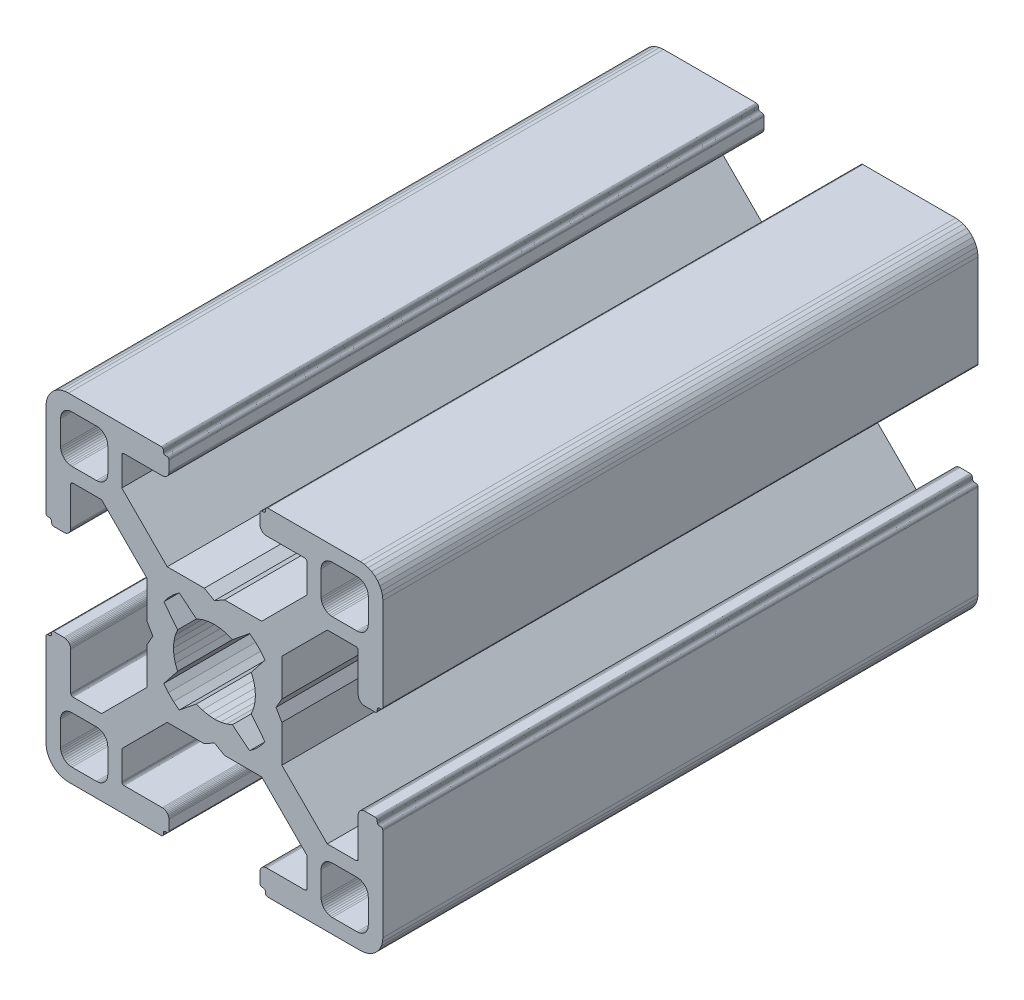
from build123d import *

# Parameters (mm, degrees)
BOSS_EXTRUDE1_DEPTH = 53


with BuildPart() as part:
    # Sketch1 → Boss-Extrude1 (new body)
    with BuildSketch(Plane.XY):
        Polygon((28.34729664, 29.969613999), (28.000000864, 29.999999329), (19.750000909, 29.999999329), (19.715268165, 29.996961355), (19.681595266, 29.987938702), (19.649999216, 29.973205179), (19.621443003, 29.953207821), (19.596790895, 29.928557575), (19.576793537, 29.899999499), (19.562061876, 29.868405312), (19.55303736, 29.834728688), (19.549999386, 29.799999669), (19.549999386, 29.699999839), (19.546961412, 29.665268958), (19.537936896, 29.631596059), (19.523203373, 29.599998146), (19.503207877, 29.571441934), (19.478557631, 29.546789825), (19.449999556, 29.526794329), (19.418403506, 29.512060806), (19.384728745, 29.503038153), (19.349999726, 29.500000179), (19.249999896, 29.500000179), (19.215267517, 29.496958527), (19.181592755, 29.487935874), (19.149996706, 29.47320235), (19.12143863, 29.453206855), (19.096788384, 29.428554746), (19.076791026, 29.399996671), (19.062057503, 29.368402484), (19.05303485, 29.334725859), (19.049996876, 29.299998703), (19.049996876, 28.39999837), (19.059110798, 28.29580945), (19.08618062, 28.194785165), (19.13038119, 28.099997016), (19.190369539, 28.014324653), (19.264324002, 27.94037019), (19.349996366, 27.88038184), (19.444784515, 27.836181271), (19.545806937, 27.809111449), (19.650010894, 27.799984574), (23.050010706, 27.799984574), (23.084741588, 27.7969466), (23.118414487, 27.787923946), (23.150012399, 27.773190423), (23.178568612, 27.753193065), (23.203220721, 27.728542819), (23.223218079, 27.699984744), (23.237949739, 27.668386831), (23.246974255, 27.634713932), (23.25001142, 27.59998608), (23.25001142, 25.049987618), (19.204474482, 20.999982084), (15.900007876, 20.999982084), (15.000008474, 20.48483404), (14.10000814, 20.999982084), (10.795543398, 20.999982084), (7.997342887, 23.801274731), (6.750011387, 25.049984589), (6.750011387, 27.599983051), (6.753049362, 27.634713932), (6.762072946, 27.668386831), (6.776805538, 27.699984744), (6.796801965, 27.728542819), (6.821454073, 27.753193065), (6.850011218, 27.773190423), (6.881607267, 27.787923946), (6.915282029, 27.7969466), (6.950011048, 27.799984574), (10.350011791, 27.799984574), (10.45420071, 27.809098497), (10.555223133, 27.836168318), (10.650011282, 27.880368888), (10.735683645, 27.940357238), (10.809638108, 28.014311701), (10.869626458, 28.099984064), (10.913827027, 28.194772213), (10.940895918, 28.295796498), (10.950010772, 28.399985417), (10.950010772, 29.299985751), (10.946974575, 29.334739239), (10.93795065, 29.368415522), (10.923215933, 29.400009153), (10.903218427, 29.428566473), (10.878566319, 29.45321765), (10.849999264, 29.473204166), (10.818403214, 29.487937689), (10.784728453, 29.496960342), (10.749999434, 29.500000179), (10.649999604, 29.500000179), (10.615270585, 29.503038153), (10.581595823, 29.512060806), (10.549999774, 29.526794329), (10.521441698, 29.546789825), (10.496791452, 29.571441934), (10.476795025, 29.599998146), (10.462061502, 29.631596059), (10.453037918, 29.665268958), (10.449999943, 29.699999839), (10.449999943, 29.799999669), (10.446961969, 29.834728688), (10.437938385, 29.868405312), (10.423205793, 29.899999499), (10.403208435, 29.928557575), (10.378557257, 29.953207821), (10.350000113, 29.973205179), (10.318404064, 29.987938702), (10.284729302, 29.996961355), (10.250000283, 29.999999329), (1.999999397, 29.999999329), (1.652702689, 29.969613999), (1.315958682, 29.879383743), (0.999999233, 29.732050374), (0.714424066, 29.532089829), (0.467910431, 29.285576195), (0.267948955, 28.999999166), (0.120614655, 28.684040532), (0.030384399, 28.34729664), (0, 28.000000864), (0, 19.750000909), (0.003037974, 19.715268165), (0.012061559, 19.681595266), (0.026795082, 19.649999216), (0.046790577, 19.621441141), (0.071442686, 19.596789032), (0.09999983, 19.576793537), (0.13159588, 19.562060013), (0.165270641, 19.55303736), (0.19999966, 19.549999386), (0.299999461, 19.549999386), (0.334728509, 19.546959549), (0.368403242, 19.537936896), (0.399999321, 19.523203373), (0.428556465, 19.503207877), (0.453208573, 19.478555769), (0.473204069, 19.449997693), (0.487937592, 19.418403506), (0.496961176, 19.384728745), (0.499999151, 19.349999726), (0.499999151, 19.249998033), (0.503038056, 19.215269014), (0.512060709, 19.181594253), (0.526794232, 19.150000066), (0.546790194, 19.121441524), (0.571441837, 19.096789882), (0.60000029, 19.076794925), (0.631595686, 19.062061999), (0.665270619, 19.053039982), (0.700000626, 19.050000801), (1.60000096, 19.050000801), (1.704189879, 19.059116587), (1.805213233, 19.086186409), (1.90000045, 19.130385115), (1.985673745, 19.190375328), (2.059627277, 19.264327928), (2.119616325, 19.350002154), (2.163816196, 19.444788441), (2.190886018, 19.545812726), (2.200000872, 19.650001645), (2.200000872, 23.050001457), (2.203039777, 23.084732338), (2.212062431, 23.118405237), (2.226795954, 23.15000315), (2.246792381, 23.178559362), (2.271443558, 23.203211471), (2.300000702, 23.223206967), (2.331596752, 23.23794049), (2.365271513, 23.246965006), (2.400001464, 23.250001117), (4.950000857, 23.250001117), (7.997332093, 20.202670812), (8.995535423, 19.204467788), (8.995535423, 15.900001182), (9.515148227, 15.00000178), (8.995535423, 14.100002378), (8.995535423, 10.795536704), (4.950000857, 6.750002138), (2.400001464, 6.750002138), (2.365271513, 6.753040112), (2.331596752, 6.762063697), (2.300000702, 6.77679722), (2.271443558, 6.796793647), (2.246792381, 6.821444824), (2.226795954, 6.850001968), (2.212062431, 6.881598018), (2.203039777, 6.915272779), (2.200000872, 6.950002729), (2.200000872, 10.350002542), (2.190896812, 10.454174265), (2.16382699, 10.555197618), (2.119627119, 10.649984836), (2.059638071, 10.735658131), (1.985684539, 10.809611663), (1.900011244, 10.869600944), (1.805224027, 10.913800582), (1.704200673, 10.940870404), (1.600011754, 10.949986189), (0.70001142, 10.949986189), (0.665281355, 10.946948596), (0.631606253, 10.937926283), (0.600010578, 10.923193954), (0.571451747, 10.903199537), (0.546799638, 10.87854836), (0.526794232, 10.850000195), (0.512060709, 10.818404146), (0.503038056, 10.784730315), (0.499999151, 10.750000365), (0.499999151, 10.650000535), (0.496961176, 10.615270585), (0.487937592, 10.581596754), (0.473204069, 10.550000705), (0.453208573, 10.521443561), (0.428556465, 10.496791452), (0.399999321, 10.476795956), (0.368403242, 10.462062433), (0.334728509, 10.453038849), (0.299999461, 10.449999943), (0.19999966, 10.449999943), (0.165270641, 10.446961969), (0.13159588, 10.437939316), (0.09999983, 10.423205793), (0.071442686, 10.403209366), (0.046790577, 10.378558189), (0.026795082, 10.350000113), (0.012061559, 10.318404064), (0.003037974, 10.284729302), (0, 10.250000283), (0, 1.999999397), (0.030384399, 1.652702689), (0.120614655, 1.315958682), (0.267948955, 0.999999233), (0.467910431, 0.714424066), (0.714424066, 0.467910431), (0.999999233, 0.267948955), (1.315958682, 0.120614655), (1.652702689, 0.030384399), (1.999999397, 0), (10.250000283, 0), (10.284729302, 0.003037974), (10.318404064, 0.012061559), (10.350000113, 0.026795082), (10.378557257, 0.046790577), (10.403208435, 0.071442686), (10.423205793, 0.09999983), (10.437938385, 0.13159588), (10.446961969, 0.165270641), (10.449999943, 0.19999966), (10.449999943, 0.300000422), (10.453037918, 0.334729441), (10.462061502, 0.368404202), (10.476795025, 0.400000252), (10.496791452, 0.428557396), (10.521441698, 0.453208573), (10.549999774, 0.473205), (10.581595823, 0.487938523), (10.615270585, 0.496961176), (10.649999604, 0.500000082), (10.749999434, 0.500000082), (10.784728453, 0.503038056), (10.818403214, 0.512060709), (10.849999264, 0.526794232), (10.878547894, 0.546800104), (10.903198606, 0.571451747), (10.923194493, 0.6000102), (10.93792742, 0.631606528), (10.946949437, 0.66528146), (10.950010772, 0.699984975), (10.950010772, 1.599985308), (10.940895918, 1.704174228), (10.913827027, 1.805197581), (10.869626458, 1.89998573), (10.809638108, 1.985658094), (10.735683645, 2.059612557), (10.650011282, 2.119600674), (10.555223133, 2.163801476), (10.45420071, 2.190870367), (10.350011791, 2.199985221), (6.950011048, 2.199985221), (6.915282029, 2.203024126), (6.881607267, 2.212046779), (6.850011218, 2.226780302), (6.821454073, 2.246776729), (6.796801965, 2.271427907), (6.776805538, 2.299985982), (6.762072946, 2.331582032), (6.753049362, 2.365256793), (6.750011387, 2.399985812), (6.750011387, 4.949985206), (9.787457566, 7.990785077), (10.795545277, 8.999985833), (14.100010019, 8.999985833), (15.000010353, 9.515133877), (15.900009756, 8.999985833), (19.204476361, 8.999985833), (20.21256413, 7.990786065), (23.25001142, 4.949988235), (23.25001142, 2.399988841), (23.246974255, 2.365256793), (23.237949739, 2.331582032), (23.223218079, 2.299985982), (23.203220721, 2.271427907), (23.178568612, 2.246776729), (23.150012399, 2.226780302), (23.118414487, 2.212046779), (23.084741588, 2.203024126), (23.050010706, 2.199985221), (19.650010894, 2.199985221), (19.545806937, 2.190883319), (19.444784515, 2.163814428), (19.349996366, 2.119613626), (19.264324002, 2.059625509), (19.190369539, 1.985671046), (19.13038119, 1.899998682), (19.08618062, 1.805210533), (19.059110798, 1.70418718), (19.049996876, 1.599998261), (19.049996876, 0.699997927), (19.053035506, 0.665268966), (19.062058795, 0.631594374), (19.076792915, 0.599998603), (19.096790813, 0.571440905), (19.121441524, 0.546790194), (19.149999978, 0.526794306), (19.181596306, 0.51206138), (19.215271238, 0.503039363), (19.249999896, 0.500000082), (19.349999726, 0.500000082), (19.384728745, 0.496961176), (19.418403506, 0.487938523), (19.449999556, 0.473205), (19.478557631, 0.453208573), (19.503207877, 0.428557396), (19.523203373, 0.400000252), (19.537936896, 0.368404202), (19.546961412, 0.334729441), (19.549999386, 0.300000422), (19.549999386, 0.19999966), (19.55303736, 0.165270641), (19.562061876, 0.13159588), (19.576793537, 0.09999983), (19.596789964, 0.071441755), (19.621442072, 0.046789646), (19.649998285, 0.02679415), (19.681594335, 0.012060627), (19.715267234, 0.003037043), (19.750000909, 0), (28.000000864, 0), (28.34729664, 0.030384399), (28.684040532, 0.120614655), (28.999999166, 0.267948955), (29.285576195, 0.467910431), (29.532089829, 0.714424066), (29.732050374, 0.999999233), (29.879383743, 1.315958682), (29.969613999, 1.652702689), (29.999999329, 1.999999397), (29.999999329, 10.250000283), (29.996974806, 10.284715361), (29.987951516, 10.318389952), (29.973217396, 10.349985723), (29.953219499, 10.378543421), (29.928568787, 10.403194133), (29.899999499, 10.423205793), (29.868405312, 10.437939316), (29.834728688, 10.446961969), (29.799999669, 10.449999943), (29.699999839, 10.449999943), (29.664909937, 10.453400043), (29.631233313, 10.462423628), (29.599637263, 10.477157151), (29.57108105, 10.497152646), (29.546427079, 10.521804755), (29.526433446, 10.550361899), (29.511699923, 10.581957949), (29.502675407, 10.615631779), (29.499637433, 10.650361729), (29.499637433, 10.750361559), (29.49697202, 10.784715548), (29.487949367, 10.818389378), (29.473215844, 10.849985428), (29.453220348, 10.878542572), (29.428568239, 10.90319468), (29.400010164, 10.923190176), (29.368415977, 10.937923699), (29.334741215, 10.946947284), (29.300012197, 10.949986189), (28.400011863, 10.949986189), (28.29581215, 10.9408876), (28.194787865, 10.913817778), (28.099999716, 10.86961814), (28.014327352, 10.809628859), (27.940374752, 10.735675327), (27.880384539, 10.650002032), (27.836185833, 10.555214814), (27.809114148, 10.454191461), (27.800000225, 10.350002542), (27.800000225, 6.950002729), (27.796962251, 6.915272779), (27.787939598, 6.881598018), (27.773206075, 6.850001968), (27.753208716, 6.821444824), (27.728558471, 6.796793647), (27.700000395, 6.77679722), (27.668404345, 6.762063697), (27.634729584, 6.753040112), (27.599998702, 6.750002138), (25.05000024, 6.750002138), (23.809199132, 7.99080223), (21.004464477, 10.795534588), (21.004464477, 14.100000262), (20.484851673, 14.999999665), (21.004464477, 15.899999067), (21.004464477, 19.204465672), (25.05000024, 23.250001117), (27.599998702, 23.250001117), (27.634729584, 23.246965006), (27.668404345, 23.23794049), (27.700000395, 23.223206967), (27.728558471, 23.203211471), (27.753208716, 23.178559362), (27.773206075, 23.15000315), (27.787939598, 23.118405237), (27.796962251, 23.084732338), (27.800000225, 23.050001457), (27.800000225, 19.650001645), (27.809114148, 19.545812726), (27.836185833, 19.444788441), (27.880384539, 19.350002154), (27.940370508, 19.264323684), (28.014323108, 19.190371084), (28.099995472, 19.130380872), (28.194783621, 19.086182165), (28.295807906, 19.059112343), (28.400001069, 19.050000801), (29.300001402, 19.050000801), (29.334730421, 19.053040638), (29.368405183, 19.062063291), (29.39999937, 19.076796814), (29.42819671, 19.097149726), (29.452848353, 19.1218023), (29.472843309, 19.150360754), (29.487576235, 19.181955219), (29.496598252, 19.215630151), (29.499637433, 19.250359227), (29.499637433, 19.35036092), (29.502675407, 19.385089939), (29.511699923, 19.4187647), (29.526433446, 19.450358887), (29.546427079, 19.478916963), (29.57108105, 19.503569071), (29.599637263, 19.523564567), (29.631233313, 19.53829809), (29.664909937, 19.547320743), (29.699999839, 19.549999386), (29.799999669, 19.549999386), (29.834728688, 19.55303736), (29.868405312, 19.562060013), (29.899999499, 19.576793537), (29.928557575, 19.596789032), (29.953207821, 19.621441141), (29.973205179, 19.649999216), (29.987938702, 19.681595266), (29.996961355, 19.715268165), (29.999999329, 19.750000909), (29.999999329, 28.000000864), (29.969613999, 28.34729664), (29.879383743, 28.684040532), (29.732050374, 28.999999166), (29.532089829, 29.285576195), (29.285576195, 29.532089829), (28.999999166, 29.732050374), (28.684040532, 29.879383743), align=None)
        Polygon((1.299998723, 25.499999523), (1.299998723, 27.699999511), (1.312309876, 27.856435627), (1.348942518, 28.009016067), (1.408992335, 28.153989464), (1.490981318, 28.287785128), (1.592892222, 28.407108039), (1.71221327, 28.50901708), (1.846008119, 28.591006994), (1.9909814, 28.651056811), (2.143563703, 28.687689453), (2.299998887, 28.699999675), (4.499998875, 28.699999675), (4.656434059, 28.687689453), (4.809016362, 28.651056811), (4.953989759, 28.591006994), (5.087784491, 28.50901708), (5.207106471, 28.407108039), (5.309016444, 28.287785128), (5.391005427, 28.153989464), (5.451056175, 28.009016067), (5.487687886, 27.856435627), (5.499999039, 27.699999511), (5.499999039, 25.499999523), (5.487687886, 25.34356527), (5.451056175, 25.190982968), (5.391005427, 25.04600957), (5.309016444, 24.912213907), (5.207106471, 24.792892858), (5.087784491, 24.690981954), (4.953989759, 24.60899204), (4.809016362, 24.548944086), (4.656434059, 24.512309581), (4.499998875, 24.499999359), (2.299998887, 24.499999359), (2.143563703, 24.512309581), (1.9909814, 24.548944086), (1.846008119, 24.60899204), (1.71221327, 24.690981954), (1.592892222, 24.792892858), (1.490981318, 24.912213907), (1.408992335, 25.04600957), (1.348942518, 25.190982968), (1.312309876, 25.34356527), align=None, mode=Mode.SUBTRACT)
        Polygon((25.34356527, 28.687689453), (25.499999523, 28.699999675), (27.699999511, 28.699999675), (27.856435627, 28.687689453), (28.009017929, 28.651056811), (28.153991327, 28.591006994), (28.28778699, 28.50901708), (28.407108039, 28.407108039), (28.50901708, 28.287785128), (28.591006994, 28.153989464), (28.651056811, 28.009016067), (28.687689453, 27.856435627), (28.700001538, 27.699999511), (28.700001538, 25.499999523), (28.687689453, 25.34356527), (28.651056811, 25.190982968), (28.591006994, 25.04600957), (28.50901708, 24.912213907), (28.407108039, 24.792892858), (28.28778699, 24.690981954), (28.153991327, 24.60899204), (28.009017929, 24.548944086), (27.856435627, 24.512309581), (27.699999511, 24.499999359), (25.499999523, 24.499999359), (25.34356527, 24.512309581), (25.190982968, 24.548944086), (25.04600957, 24.60899204), (24.912215769, 24.690981954), (24.792892858, 24.792892858), (24.690981954, 24.912213907), (24.608993903, 25.04600957), (24.548944086, 25.190982968), (24.512311444, 25.34356527), (24.500001222, 25.499999523), (24.500001222, 27.699999511), (24.512311444, 27.856435627), (24.548944086, 28.009016067), (24.608993903, 28.153989464), (24.690981954, 28.287785128), (24.792892858, 28.407108039), (24.912215769, 28.50901708), (25.04600957, 28.591006994), (25.190982968, 28.651056811), align=None, mode=Mode.SUBTRACT)
        Polygon((14.999999665, 18.649999052), (15.550030395, 18.608318642), (16.087498516, 18.484227359), (16.600128263, 18.280562013), (18.13592948, 19.518401474), (18.644984812, 19.11874488), (19.103571773, 18.662061542), (19.505336881, 18.154669553), (18.280562013, 16.600130126), (18.484227359, 16.087498516), (18.608318642, 15.550030395), (18.649999052, 14.999999665), (18.608318642, 14.449968934), (18.484227359, 13.912500814), (18.280562013, 13.399870135), (19.505336881, 11.845329776), (19.103571773, 11.337937787), (18.644984812, 10.881252587), (18.13592948, 10.481598787), (16.600128263, 11.719437316), (16.087498516, 11.515771039), (15.550030395, 11.391680688), (14.999999665, 11.349999346), (14.449968934, 11.391680688), (13.912500814, 11.515771039), (13.399870135, 11.719437316), (11.864069849, 10.481598787), (11.355013587, 10.881252587), (10.896427557, 11.337937787), (10.494662449, 11.845329776), (11.719438247, 13.399870135), (11.515771039, 13.912500814), (11.391680688, 14.449968934), (11.349999346, 14.999999665), (11.391680688, 15.550030395), (11.515771039, 16.087498516), (11.719438247, 16.600130126), (10.494662449, 18.154669553), (10.896427557, 18.662061542), (11.355013587, 19.11874488), (11.864069849, 19.518401474), (13.399870135, 18.280562013), (13.912500814, 18.484227359), (14.449968934, 18.608318642), align=None, mode=Mode.SUBTRACT)
        Polygon((4.499998875, 1.299999771), (2.299998887, 1.299999771), (2.143563703, 1.312310807), (1.9909814, 1.348942518), (1.846008119, 1.408992335), (1.71221327, 1.490982249), (1.592892222, 1.592892222), (1.490981318, 1.712214202), (1.408992335, 1.846008934), (1.348942518, 1.990982331), (1.312309876, 2.143564634), (1.299998723, 2.299998887), (1.299998723, 4.499999806), (1.312309876, 4.656434059), (1.348942518, 4.809017293), (1.408992335, 4.95399069), (1.490981318, 5.087785423), (1.592892222, 5.207106471), (1.71221327, 5.309017375), (1.846008119, 5.391006358), (1.9909814, 5.451056175), (2.143563703, 5.487688817), (2.299998887, 5.49999997), (4.499998875, 5.49999997), (4.656434059, 5.487688817), (4.809016362, 5.451056175), (4.953989759, 5.391006358), (5.087784491, 5.309017375), (5.207106471, 5.207106471), (5.309016444, 5.087785423), (5.391005427, 4.95399069), (5.451056175, 4.809017293), (5.487687886, 4.656434059), (5.499999039, 4.499999806), (5.499999039, 2.299998887), (5.487687886, 2.143564634), (5.451056175, 1.990982331), (5.391005427, 1.846008934), (5.309016444, 1.712214202), (5.207106471, 1.592892222), (5.087784491, 1.490982249), (4.953989759, 1.408992335), (4.809016362, 1.348942518), (4.656434059, 1.312310807), align=None, mode=Mode.SUBTRACT)
        Polygon((27.699999511, 1.299999771), (25.499999523, 1.299999771), (25.34356527, 1.312310807), (25.190982968, 1.348942518), (25.04600957, 1.408992335), (24.912215769, 1.490982249), (24.792892858, 1.592892222), (24.690981954, 1.712214202), (24.608993903, 1.846008934), (24.548944086, 1.990982331), (24.512311444, 2.143564634), (24.500001222, 2.299998887), (24.500001222, 4.499999806), (24.512311444, 4.656434059), (24.548944086, 4.809017293), (24.608993903, 4.95399069), (24.690981954, 5.087785423), (24.792892858, 5.207106471), (24.912215769, 5.309017375), (25.04600957, 5.391006358), (25.190982968, 5.451056175), (25.34356527, 5.487688817), (25.499999523, 5.49999997), (27.699999511, 5.49999997), (27.856435627, 5.487688817), (28.009017929, 5.451056175), (28.153991327, 5.391006358), (28.28778699, 5.309017375), (28.407108039, 5.207106471), (28.50901708, 5.087785423), (28.591006994, 4.95399069), (28.651056811, 4.809017293), (28.687689453, 4.656434059), (28.700001538, 4.499999806), (28.700001538, 2.299998887), (28.687689453, 2.143564634), (28.651056811, 1.990982331), (28.591006994, 1.846008934), (28.50901708, 1.712214202), (28.407108039, 1.592892222), (28.28778699, 1.490982249), (28.153991327, 1.408992335), (28.009017929, 1.348942518), (27.856435627, 1.312310807), align=None, mode=Mode.SUBTRACT)
    extrude(amount=-BOSS_EXTRUDE1_DEPTH)


solid = part.part
